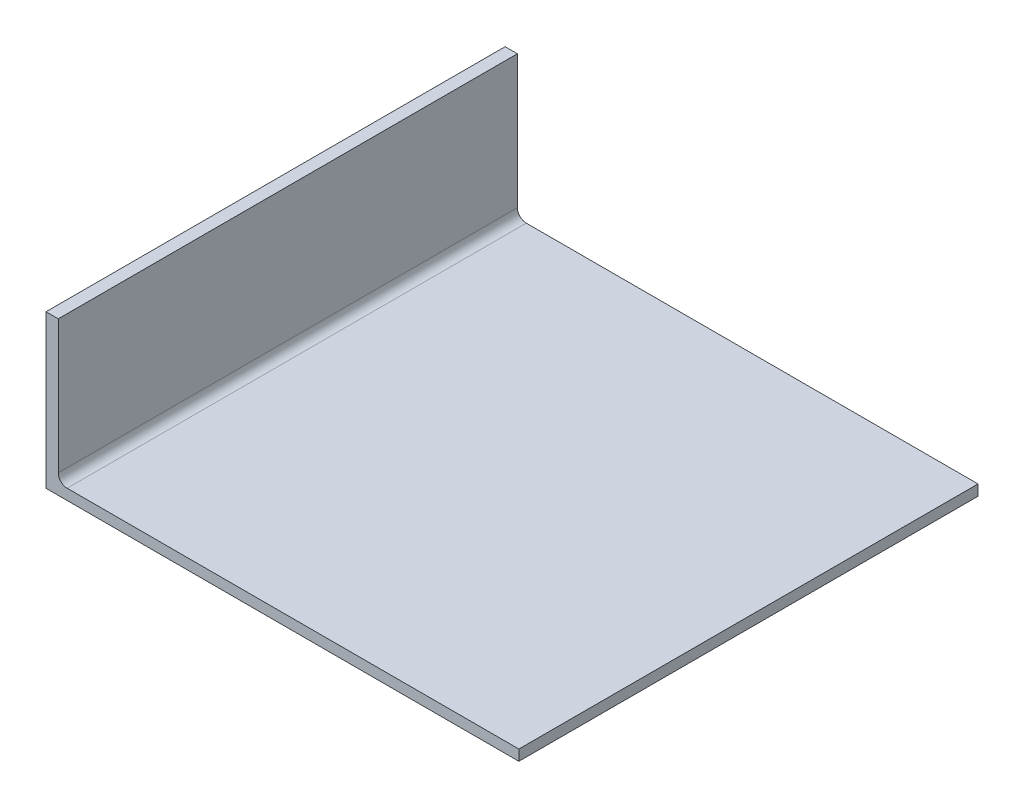
from build123d import *

# Parameters (mm, degrees)
SKETCH1_W           = 265.950423439
SKETCH1_H           = 258.221174697
BASE_DEPTH          = 6
SKETCH2_W           = 6.892214754
SKETCH2_H           = 258.221174697
BOSS_EXTRUDE2_DEPTH = 80
FILLET1_R           = 5


with BuildPart() as part:
    # Sketch1 → Base (new body)
    with BuildSketch(Plane(origin=(0, 0, 0), x_dir=(1, 0, 0), z_dir=(0, 1, 0))):
        with Locations((-129.157291203, -107.886320424)):
            Rectangle(SKETCH1_W, SKETCH1_H)
    extrude(amount=BASE_DEPTH)

    # Sketch2 → Boss-Extrude2 (add)
    with BuildSketch(Plane(origin=(0, 6, 0), x_dir=(1, 0, 0), z_dir=(0, 1, 0))):
        with Locations((-258.686395546, -107.886320424)):
            Rectangle(SKETCH2_W, SKETCH2_H)
    extrude(amount=BOSS_EXTRUDE2_DEPTH)

    # Fillet1
    fillet1_edges = [part.edges().sort_by_distance(p)[0] for p in [
        (-255.240288169, 6, 107.886320423),
    ]]
    fillet(fillet1_edges, radius=FILLET1_R)


solid = part.part
